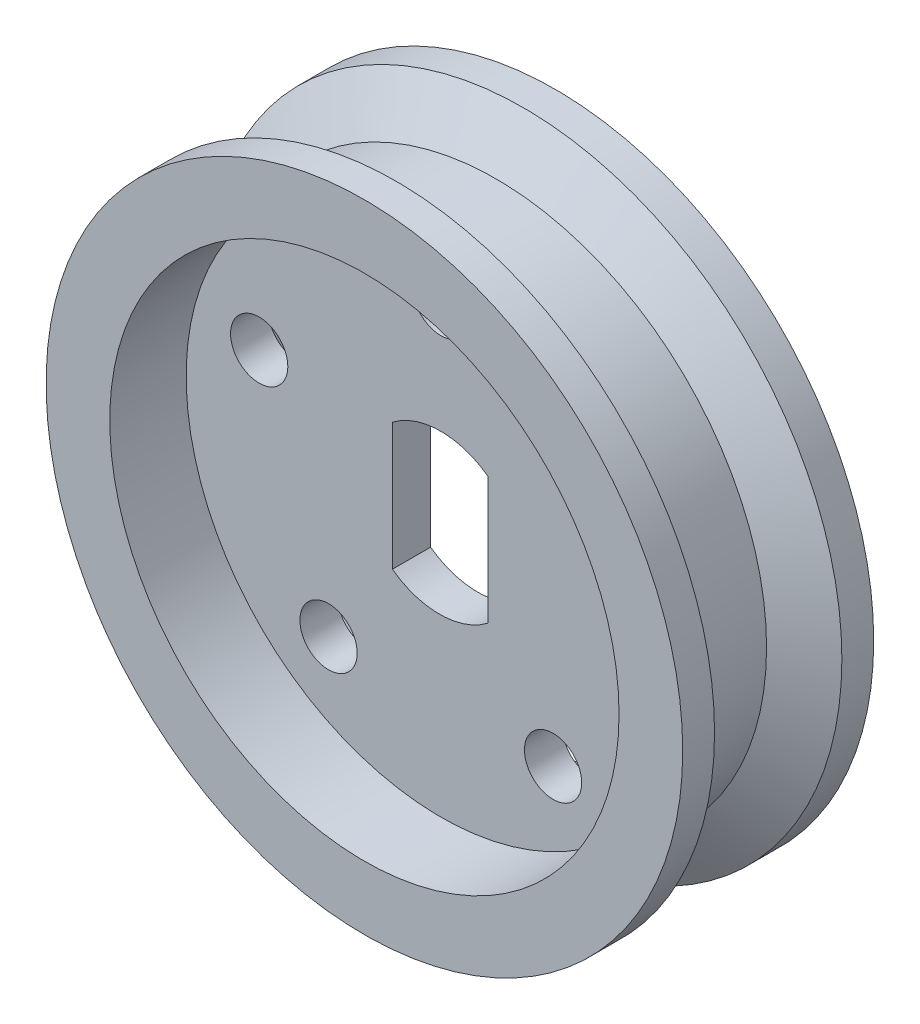
from build123d import *

# Parameters (mm, degrees)
SKETCH1_R           = 10
BOSS_EXTRUDE1_DEPTH = 3
SKETCH2_R           = 8
CUT_EXTRUDE1_DEPTH  = 2.4
SKETCH3_R           = 0.9
CUT_EXTRUDE3_DEPTH  = 4.6


with BuildPart() as part:
    # Sketch1 → Boss-Extrude1 (new body, symmetric)
    with BuildSketch(Plane.XY):
        Circle(SKETCH1_R)
        with BuildLine():
            Line((-1.521572539, 1.983637318), (-1.521572539, -2.016362682))
            ThreePointArc((-1.521572539, -2.016362682), (-0.016245384, -2.500087973), (1.478251514, -1.983871914))
            Line((1.478251514, -1.983871914), (1.478251514, 2.016128086))
            ThreePointArc((1.478251514, 2.016128086), (-0.02707564, 2.499853378), (-1.521572539, 1.983637318))
        make_face(mode=Mode.SUBTRACT)
    extrude(amount=BOSS_EXTRUDE1_DEPTH, both=True)

    # Sketch2 → Cut-Extrude1 (cut)
    with BuildSketch(Plane.XY.offset(3)):
        Circle(SKETCH2_R)
    cut_extrude1 = extrude(amount=-CUT_EXTRUDE1_DEPTH, mode=Mode.SUBTRACT)

    # Mirror1: Cut-Extrude1 across plane
    add(cut_extrude1.mirror(Plane.XY), mode=Mode.SUBTRACT)

    # Sketch5 → Cut-Revolve1 (revolve, cut)
    with BuildSketch(Plane(origin=(0, 0, 0), x_dir=(1, 0, 0), z_dir=(0, 1, 0))):
        Polygon((-10, 2), (-8.5, 1.133974596), (-8.5, -1.133974596), (-10, -2), align=None)
    revolve(axis=Axis((0, 0, 0), (0, 0, -1)), mode=Mode.SUBTRACT)

    # Sketch3 → Cut-Extrude3 (cut, through all)
    with BuildSketch(Plane.XY.offset(0.6)):
        with Locations((-3.526711514, -4.854101966)):
            Circle(SKETCH3_R)
        with Locations((0, 6)):
            Circle(SKETCH3_R)
        with Locations((5.706339098, 1.854101966)):
            Circle(SKETCH3_R)
        with Locations((3.526711514, -4.854101966)):
            Circle(SKETCH3_R)
        with Locations((-5.706339098, 1.854101966)):
            Circle(SKETCH3_R)
    extrude(amount=-CUT_EXTRUDE3_DEPTH, mode=Mode.SUBTRACT)


solid = part.part
